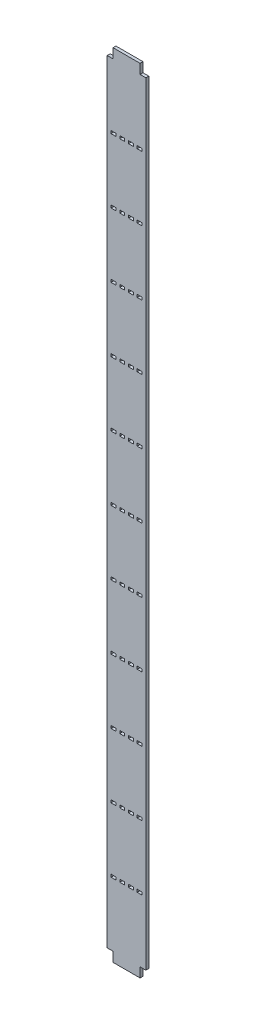
from build123d import *

# Parameters (mm, degrees)
SKETCH_1_W                 = 20
SKETCH_1_H                 = 410
EXTRUDE_1_DEPTH            = 1.5
CUT_EXTRUDE_1_REACH        = 3.5
SKETCH_2_W                 = 3
SKETCH_2_H                 = 5
SKETCH_3_W                 = 2.5
SKETCH_3_H                 = 1.4
CUT_EXTRUDE_2_DEPTH        = 1.5
PATTERN_LINEAR_1_COUNT     = 6
PATTERN_LINEAR_1_PITCH     = 33.33
PATTERN_LINEAR_1_COL_COUNT = 6
PATTERN_LINEAR_1_COL_PITCH = 33.33


with BuildPart() as part:
    # 草图1 → 凸台-拉伸1 (new body)
    with BuildSketch(Plane.XY):
        Rectangle(SKETCH_1_W, SKETCH_1_H)
    extrude(amount=EXTRUDE_1_DEPTH)

    # 草图2 → 切除-拉伸1 (cut, up to next)
    with BuildSketch(Plane.XY.offset(1.5), mode=Mode.PRIVATE) as cut_extrude_1_sk1:
        with Locations((-8.5, 202.5)):
            Rectangle(SKETCH_2_W, SKETCH_2_H)
    cut_extrude_1_tool1 = extrude(cut_extrude_1_sk1.sketch, amount=-CUT_EXTRUDE_1_REACH, mode=Mode.PRIVATE) & part.part
    add(cut_extrude_1_tool1.solids().sort_by_distance((-8.5, 202.5, 1.5))[0], mode=Mode.SUBTRACT)
    # 草图2 → 切除-拉伸1 (cut, up to next)
    with BuildSketch(Plane.XY.offset(1.5), mode=Mode.PRIVATE) as cut_extrude_1_sk2:
        with Locations((8.5, 202.5)):
            Rectangle(SKETCH_2_W, SKETCH_2_H)
    cut_extrude_1_tool2 = extrude(cut_extrude_1_sk2.sketch, amount=-CUT_EXTRUDE_1_REACH, mode=Mode.PRIVATE) & part.part
    add(cut_extrude_1_tool2.solids().sort_by_distance((8.5, 202.5, 1.5))[0], mode=Mode.SUBTRACT)
    # 草图2 → 切除-拉伸1 (cut, up to next)
    with BuildSketch(Plane.XY.offset(1.5), mode=Mode.PRIVATE) as cut_extrude_1_sk3:
        with Locations((-8.5, -202.5)):
            Rectangle(SKETCH_2_W, SKETCH_2_H)
    cut_extrude_1_tool3 = extrude(cut_extrude_1_sk3.sketch, amount=-CUT_EXTRUDE_1_REACH, mode=Mode.PRIVATE) & part.part
    add(cut_extrude_1_tool3.solids().sort_by_distance((-8.5, -202.5, 1.5))[0], mode=Mode.SUBTRACT)
    # 草图2 → 切除-拉伸1 (cut, up to next)
    with BuildSketch(Plane.XY.offset(1.5), mode=Mode.PRIVATE) as cut_extrude_1_sk4:
        with Locations((8.5, -202.5)):
            Rectangle(SKETCH_2_W, SKETCH_2_H)
    cut_extrude_1_tool4 = extrude(cut_extrude_1_sk4.sketch, amount=-CUT_EXTRUDE_1_REACH, mode=Mode.PRIVATE) & part.part
    add(cut_extrude_1_tool4.solids().sort_by_distance((8.5, -202.5, 1.5))[0], mode=Mode.SUBTRACT)

    # 草图3 → 切除-拉伸2 (cut)
    with BuildSketch(Plane.XY.offset(1.5)):
        with Locations((-6.75, 0)):
            Rectangle(SKETCH_3_W, SKETCH_3_H)
        with Locations((-2.25, 0)):
            Rectangle(SKETCH_3_W, SKETCH_3_H)
        with Locations((2.25, 0)):
            Rectangle(SKETCH_3_W, SKETCH_3_H)
        with Locations((6.75, 0)):
            Rectangle(SKETCH_3_W, SKETCH_3_H)
    cut_extrude_2 = extrude(amount=-CUT_EXTRUDE_2_DEPTH, mode=Mode.SUBTRACT)

    # 阵列(线性)1: 切除-拉伸2 ×6
    with Locations(*[(0, -i * PATTERN_LINEAR_1_PITCH, 0) for i in range(1, PATTERN_LINEAR_1_COUNT)]):
        add(cut_extrude_2, mode=Mode.SUBTRACT)

    # 阵列(线性)1 col: 切除-拉伸2 ×6
    with Locations(*[(0, i * PATTERN_LINEAR_1_COL_PITCH, 0) for i in range(1, PATTERN_LINEAR_1_COL_COUNT)]):
        add(cut_extrude_2, mode=Mode.SUBTRACT)


solid = part.part
